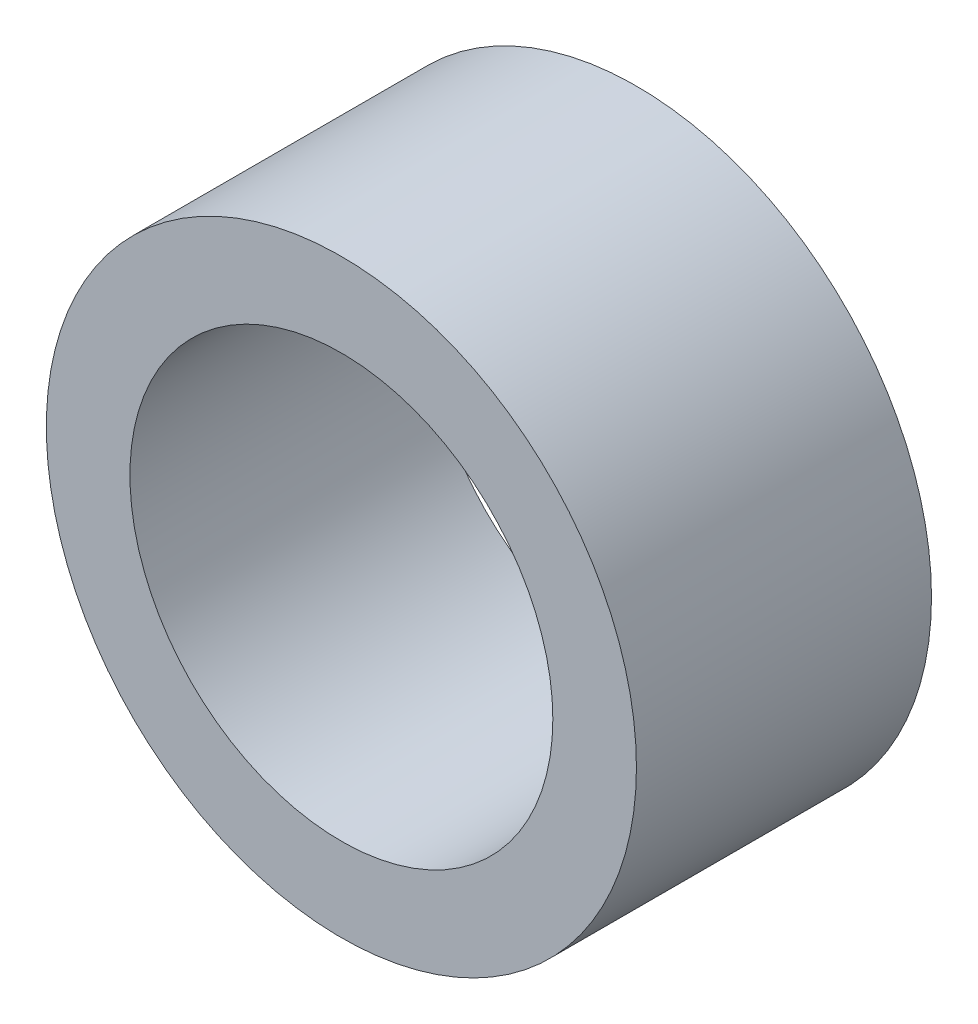
from build123d import *

# Parameters (mm, degrees)
SKETCH1_R           = 3
SKETCH1_R_2         = 2.15
BOSS_EXTRUDE1_DEPTH = 3


with BuildPart() as part:
    # Sketch1 → Boss-Extrude1 (new body)
    with BuildSketch(Plane.XY):
        Circle(SKETCH1_R)
        Circle(SKETCH1_R_2, mode=Mode.SUBTRACT)
    extrude(amount=BOSS_EXTRUDE1_DEPTH)


solid = part.part
